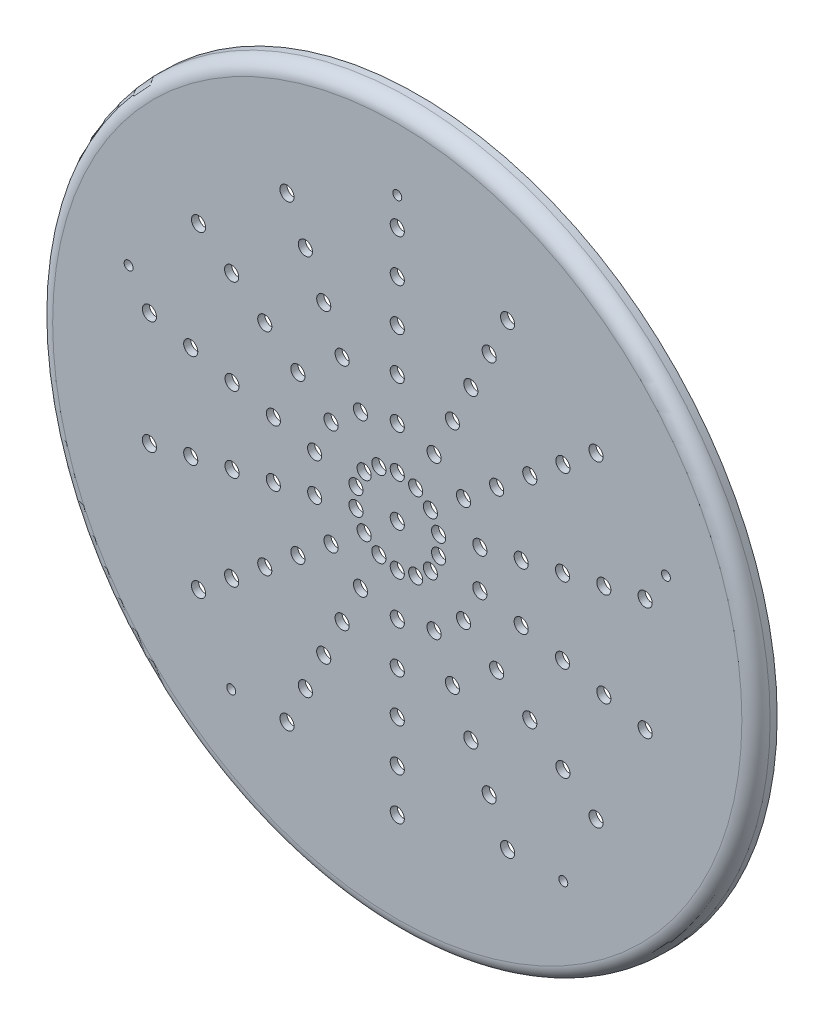
from build123d import *

# Parameters (mm, degrees)
SKETCH2_R           = 254
BOSS_EXTRUDE1_DEPTH = 15
FILLET1_R           = 10
SHELL1_T            = -5
SKETCH3_7_R         = 3.175
CUT_EXTRUDE1_DEPTH  = 10
SKETCH3_R           = 4.175
SKETCH3_R_2         = 3.175
EXTRUDE_THIN1_DEPTH = 10
SKETCH5_R           = 5
CUT_EXTRUDE3_DEPTH  = 10


with BuildPart() as part:
    # Sketch2 → Boss-Extrude1 (new body)
    with BuildSketch(Plane.XY):
        Circle(SKETCH2_R)
    extrude(amount=BOSS_EXTRUDE1_DEPTH)

    # Fillet1
    fillet1_edges = [part.edges().sort_by_distance(p)[0] for p in [
        (-254, 0, 15),
    ]]
    fillet(fillet1_edges, radius=FILLET1_R)

    # Shell1
    shell1_openings = [part.faces().sort_by_distance(p)[0] for p in [
        (0, 0, 0),
    ]]
    offset(amount=SHELL1_T, openings=shell1_openings, kind=Kind.INTERSECTION)

    # Sketch3_7 → Cut-Extrude1 (cut)
    with BuildSketch(Plane.XY.offset(15)):
        with Locations((0, 200)):
            Circle(SKETCH3_7_R)
        with Locations((190.211303259, 61.803398875)):
            Circle(SKETCH3_7_R)
        with Locations((117.557050459, -161.803398875)):
            Circle(SKETCH3_7_R)
        with Locations((-117.557050458, -161.803398875)):
            Circle(SKETCH3_7_R)
        with Locations((-190.211303259, 61.803398875)):
            Circle(SKETCH3_7_R)
    extrude(amount=-CUT_EXTRUDE1_DEPTH, mode=Mode.SUBTRACT)

    # Sketch3 → Extrude-Thin1 (add)
    # profile 1 of 5: a face of its own
    with BuildSketch(Plane.XY.offset(15)):
        with Locations((0, 200)):
            Circle(SKETCH3_R)
        with Locations((0, 200)):
            Circle(SKETCH3_R_2, mode=Mode.SUBTRACT)
    # profile 2 of 5: a face of its own
    with BuildSketch(Plane.XY.offset(15)):
        with Locations((190.211303259, 61.803398875)):
            Circle(SKETCH3_R)
        with Locations((190.211303259, 61.803398875)):
            Circle(SKETCH3_R_2, mode=Mode.SUBTRACT)
    # profile 3 of 5: a face of its own
    with BuildSketch(Plane.XY.offset(15)):
        with Locations((117.557050459, -161.803398875)):
            Circle(SKETCH3_R)
        with Locations((117.557050459, -161.803398875)):
            Circle(SKETCH3_R_2, mode=Mode.SUBTRACT)
    # profile 4 of 5: a face of its own
    with BuildSketch(Plane.XY.offset(15)):
        with Locations((-117.557050458, -161.803398875)):
            Circle(SKETCH3_R)
        with Locations((-117.557050458, -161.803398875)):
            Circle(SKETCH3_R_2, mode=Mode.SUBTRACT)
    # profile 5 of 5: a face of its own
    with BuildSketch(Plane.XY.offset(15)):
        with Locations((-190.211303259, 61.803398875)):
            Circle(SKETCH3_R)
        with Locations((-190.211303259, 61.803398875)):
            Circle(SKETCH3_R_2, mode=Mode.SUBTRACT)
    extrude(amount=-EXTRUDE_THIN1_DEPTH)

    # Sketch5 → Cut-Extrude3 (cut)
    with BuildSketch(Plane(origin=(0, 0, 10), x_dir=(-1, 0, 0), z_dir=(0, 0, -1))):
        with Locations((0, 180)):
            Circle(SKETCH5_R)
        with Locations((0, 150)):
            Circle(SKETCH5_R)
        with Locations((0, 120)):
            Circle(SKETCH5_R)
        with Locations((0, 90)):
            Circle(SKETCH5_R)
        with Locations((0, 60)):
            Circle(SKETCH5_R)
        with Locations((0, 30)):
            Circle(SKETCH5_R)
        Circle(SKETCH5_R)
        with Locations((13.016512174, 27.029066037)):
            Circle(SKETCH5_R)
        with Locations((26.033024347, 54.058132074)):
            Circle(SKETCH5_R)
        with Locations((39.049536521, 81.087198111)):
            Circle(SKETCH5_R)
        with Locations((52.066048694, 108.116264148)):
            Circle(SKETCH5_R)
        with Locations((65.082560868, 135.145330185)):
            Circle(SKETCH5_R)
        with Locations((78.099073041, 162.174396222)):
            Circle(SKETCH5_R)
        with Locations((23.454944474, 18.704694056)):
            Circle(SKETCH5_R)
        with Locations((46.909888948, 37.409388112)):
            Circle(SKETCH5_R)
        with Locations((70.364833422, 56.114082167)):
            Circle(SKETCH5_R)
        with Locations((93.819777896, 74.818776223)):
            Circle(SKETCH5_R)
        with Locations((117.27472237, 93.523470279)):
            Circle(SKETCH5_R)
        with Locations((140.729666844, 112.228164335)):
            Circle(SKETCH5_R)
        with Locations((29.247837365, 6.675628019)):
            Circle(SKETCH5_R)
        with Locations((58.495674731, 13.351256037)):
            Circle(SKETCH5_R)
        with Locations((87.743512096, 20.026884056)):
            Circle(SKETCH5_R)
        with Locations((116.991349462, 26.702512075)):
            Circle(SKETCH5_R)
        with Locations((146.239186827, 33.378140093)):
            Circle(SKETCH5_R)
        with Locations((175.487024193, 40.053768112)):
            Circle(SKETCH5_R)
        with Locations((29.247837365, -6.675628019)):
            Circle(SKETCH5_R)
        with Locations((58.495674731, -13.351256037)):
            Circle(SKETCH5_R)
        with Locations((87.743512096, -20.026884056)):
            Circle(SKETCH5_R)
        with Locations((116.991349462, -26.702512075)):
            Circle(SKETCH5_R)
        with Locations((146.239186827, -33.378140093)):
            Circle(SKETCH5_R)
        with Locations((175.487024193, -40.053768112)):
            Circle(SKETCH5_R)
        with Locations((23.454944474, -18.704694056)):
            Circle(SKETCH5_R)
        with Locations((46.909888948, -37.409388112)):
            Circle(SKETCH5_R)
        with Locations((70.364833422, -56.114082167)):
            Circle(SKETCH5_R)
        with Locations((93.819777896, -74.818776223)):
            Circle(SKETCH5_R)
        with Locations((117.27472237, -93.523470279)):
            Circle(SKETCH5_R)
        with Locations((140.729666844, -112.228164335)):
            Circle(SKETCH5_R)
        with Locations((13.016512174, -27.029066037)):
            Circle(SKETCH5_R)
        with Locations((26.033024347, -54.058132074)):
            Circle(SKETCH5_R)
        with Locations((39.049536521, -81.087198111)):
            Circle(SKETCH5_R)
        with Locations((52.066048694, -108.116264148)):
            Circle(SKETCH5_R)
        with Locations((65.082560868, -135.145330185)):
            Circle(SKETCH5_R)
        with Locations((78.099073041, -162.174396222)):
            Circle(SKETCH5_R)
        with Locations((0, -30)):
            Circle(SKETCH5_R)
        with Locations((0, -60)):
            Circle(SKETCH5_R)
        with Locations((0, -90)):
            Circle(SKETCH5_R)
        with Locations((0, -120)):
            Circle(SKETCH5_R)
        with Locations((0, -150)):
            Circle(SKETCH5_R)
        with Locations((0, -180)):
            Circle(SKETCH5_R)
        with Locations((-13.016512174, -27.029066037)):
            Circle(SKETCH5_R)
        with Locations((-26.033024347, -54.058132074)):
            Circle(SKETCH5_R)
        with Locations((-39.049536521, -81.087198111)):
            Circle(SKETCH5_R)
        with Locations((-52.066048694, -108.116264148)):
            Circle(SKETCH5_R)
        with Locations((-65.082560868, -135.145330185)):
            Circle(SKETCH5_R)
        with Locations((-78.099073041, -162.174396222)):
            Circle(SKETCH5_R)
        with Locations((-23.454944474, -18.704694056)):
            Circle(SKETCH5_R)
        with Locations((-46.909888948, -37.409388112)):
            Circle(SKETCH5_R)
        with Locations((-70.364833422, -56.114082167)):
            Circle(SKETCH5_R)
        with Locations((-93.819777896, -74.818776223)):
            Circle(SKETCH5_R)
        with Locations((-117.27472237, -93.523470279)):
            Circle(SKETCH5_R)
        with Locations((-140.729666844, -112.228164335)):
            Circle(SKETCH5_R)
        with Locations((-29.247837365, -6.675628019)):
            Circle(SKETCH5_R)
        with Locations((-58.495674731, -13.351256037)):
            Circle(SKETCH5_R)
        with Locations((-87.743512096, -20.026884056)):
            Circle(SKETCH5_R)
        with Locations((-116.991349462, -26.702512075)):
            Circle(SKETCH5_R)
        with Locations((-146.239186827, -33.378140093)):
            Circle(SKETCH5_R)
        with Locations((-175.487024193, -40.053768112)):
            Circle(SKETCH5_R)
        with Locations((-29.247837365, 6.675628019)):
            Circle(SKETCH5_R)
        with Locations((-58.495674731, 13.351256037)):
            Circle(SKETCH5_R)
        with Locations((-87.743512096, 20.026884056)):
            Circle(SKETCH5_R)
        with Locations((-116.991349462, 26.702512075)):
            Circle(SKETCH5_R)
        with Locations((-146.239186827, 33.378140093)):
            Circle(SKETCH5_R)
        with Locations((-175.487024193, 40.053768112)):
            Circle(SKETCH5_R)
        with Locations((-23.454944474, 18.704694056)):
            Circle(SKETCH5_R)
        with Locations((-46.909888948, 37.409388112)):
            Circle(SKETCH5_R)
        with Locations((-70.364833422, 56.114082167)):
            Circle(SKETCH5_R)
        with Locations((-93.819777896, 74.818776223)):
            Circle(SKETCH5_R)
        with Locations((-117.27472237, 93.523470279)):
            Circle(SKETCH5_R)
        with Locations((-140.729666844, 112.228164335)):
            Circle(SKETCH5_R)
        with Locations((-13.016512174, 27.029066037)):
            Circle(SKETCH5_R)
        with Locations((-26.033024347, 54.058132074)):
            Circle(SKETCH5_R)
        with Locations((-39.049536521, 81.087198111)):
            Circle(SKETCH5_R)
        with Locations((-52.066048694, 108.116264148)):
            Circle(SKETCH5_R)
        with Locations((-65.082560868, 135.145330185)):
            Circle(SKETCH5_R)
        with Locations((-78.099073041, 162.174396222)):
            Circle(SKETCH5_R)
    extrude(amount=-CUT_EXTRUDE3_DEPTH, mode=Mode.SUBTRACT)


solid = part.part
